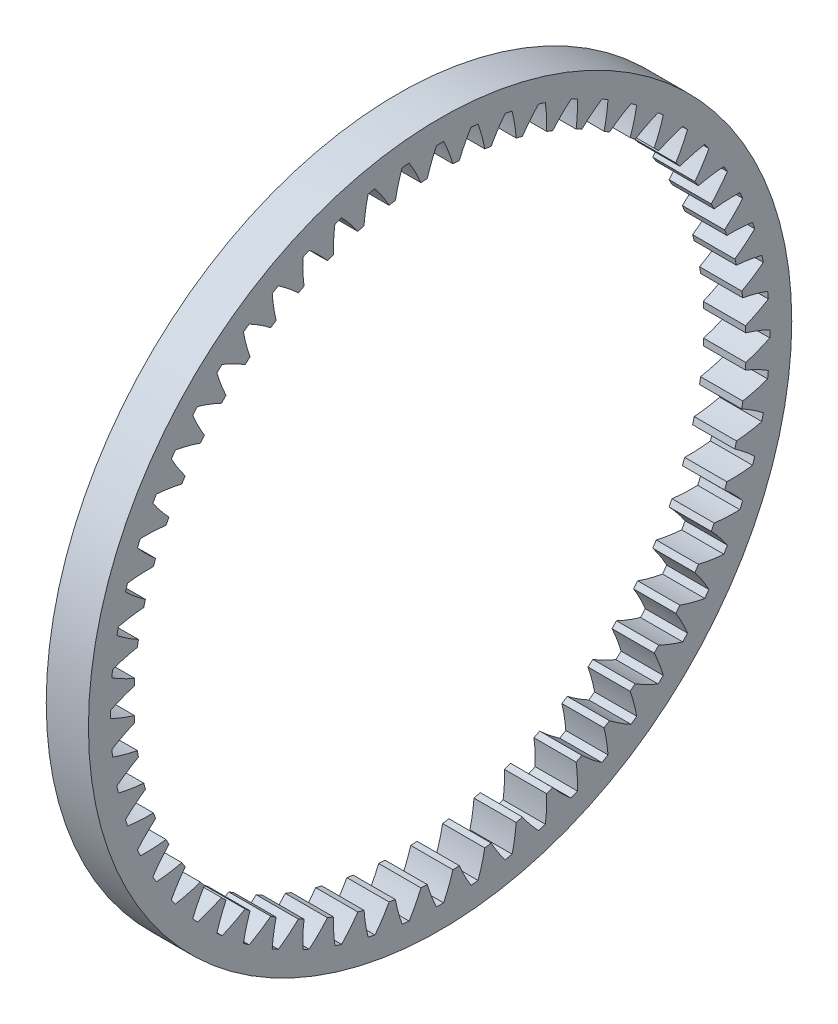
from build123d import *

# Parameters (mm, degrees)
BASPROSKE_W     = 12
BASPROSKE_H     = 13
TOOTHCUT_DEPTH  = 142.929559994
TEETHCUTS_COUNT = 60
TEETHCUTS_ANGLE = 354


with BuildPart() as part:
    # BasProSke → Base-Revolve (revolve)
    with BuildSketch(Plane(origin=(0, 0, 0), x_dir=(1, 0, 0), z_dir=(0, 1, 0))):
        with Locations((6, 93.5)):
            Rectangle(BASPROSKE_W, BASPROSKE_H)
    revolve(axis=Axis((-10, 0, 0), (1, 0, 0)))

    # TooCutSke → ToothCut (cut, through all)
    with BuildSketch(Plane(origin=(0, 0, 0), x_dir=(0, 0, -1), z_dir=(1, 0, 0))):
        with BuildLine():
            ThreePointArc((3.64944484, 86.898001114), (2.46565463, 90.375900508), (1.002106965, 93.745644073))
            ThreePointArc((1.002106965, 93.745644073), (0, 93.751), (-1.002106965, 93.745644073))
            ThreePointArc((-1.002106965, 93.745644073), (-2.46565463, 90.375900508), (-3.64944484, 86.898001114))
            ThreePointArc((-3.64944484, 86.898001114), (0, 86.9746), (3.64944484, 86.898001114))
        make_face()
    toothcut = extrude(amount=TOOTHCUT_DEPTH, mode=Mode.SUBTRACT)

    # TeethCuts: ToothCut ×60 about axis
    teethcuts_axis = Axis((-10, 0, 0), (1, 0, 0))
    for i in range(1, TEETHCUTS_COUNT):
        add(toothcut.rotate(teethcuts_axis, i * TEETHCUTS_ANGLE / (TEETHCUTS_COUNT - 1)), mode=Mode.SUBTRACT)


solid = part.part
